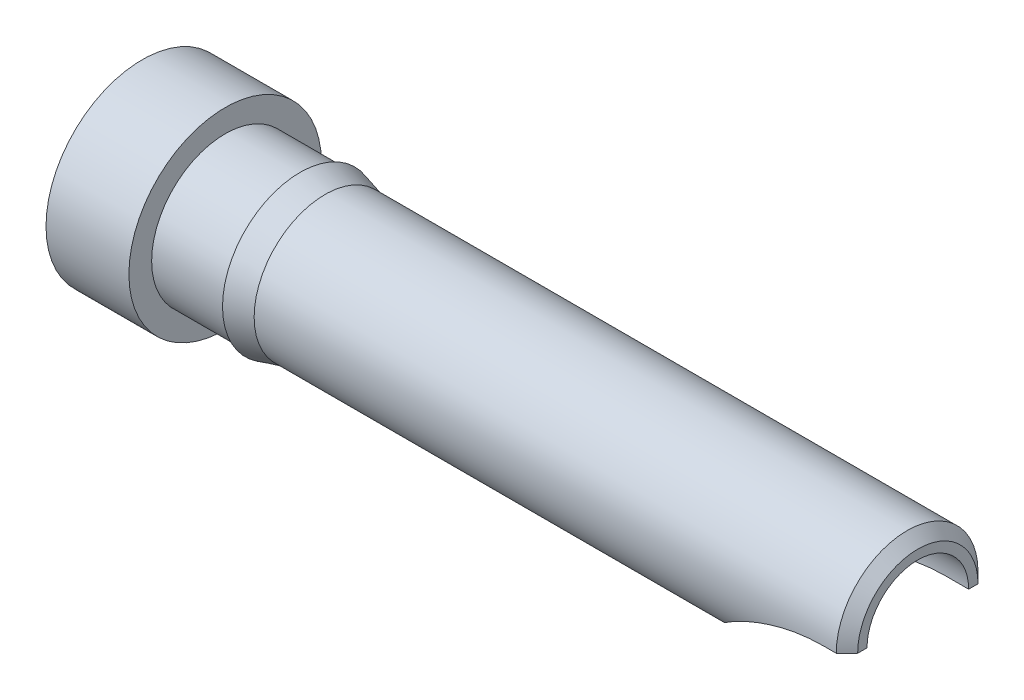
from build123d import *

# Parameters (mm, degrees)
HOLE1_D             = 0.9652
HOLE1_DEPTH         = 2.286
HOLE1_TIP           = 0.289975335
EXTRUDE1_DEPTH      = 0.6731
EXTRUDE1_DEPTH_BACK = 0.6731


with BuildPart() as part:
    # Sketch1 → RevolutionAngle1 (revolve)
    with BuildSketch(Plane.XY):
        Polygon((7.2644, 0.6731), (7.366, 0.5715), (7.366, 0), (0, 0), (0, 0.9144), (0.7874, 0.9144), (0.7874, 0.6985), (1.4986, 0.6985), (1.4986, 0.7366), (1.735585226, 0.6731), align=None)
    revolve(axis=Axis((0, 0, 0), (1, 0, 0)))

    # Hole1
    with Locations(Plane(origin=(7.366, 0, 0), x_dir=(0, 0, 1), z_dir=(1, 0, 0))):
        with Locations((0, 0)):
            Hole(HOLE1_D / 2, depth=HOLE1_DEPTH)
            with Locations((0, 0, -(HOLE1_DEPTH + HOLE1_TIP / 2))):  # 118° drill point
                Cone(0, HOLE1_D / 2, HOLE1_TIP, mode=Mode.SUBTRACT)

    # Sketch6 → Extrude1 (cut, two sides: drawn at the far end of the back side and taken through both)
    with BuildSketch(Plane.XY.offset(-EXTRUDE1_DEPTH_BACK)):
        with BuildLine():
            Line((5.842, -0.6731), (7.366, -0.6731))
            Line((7.366, -0.6731), (7.366, 0))
            Line((7.366, 0), (7.146272069, 0))
            ThreePointArc((7.146272069, 0), (6.412414242, -0.17819693), (5.842, -0.6731))
        make_face()
    extrude(amount=EXTRUDE1_DEPTH + EXTRUDE1_DEPTH_BACK, mode=Mode.SUBTRACT)


solid = part.part
